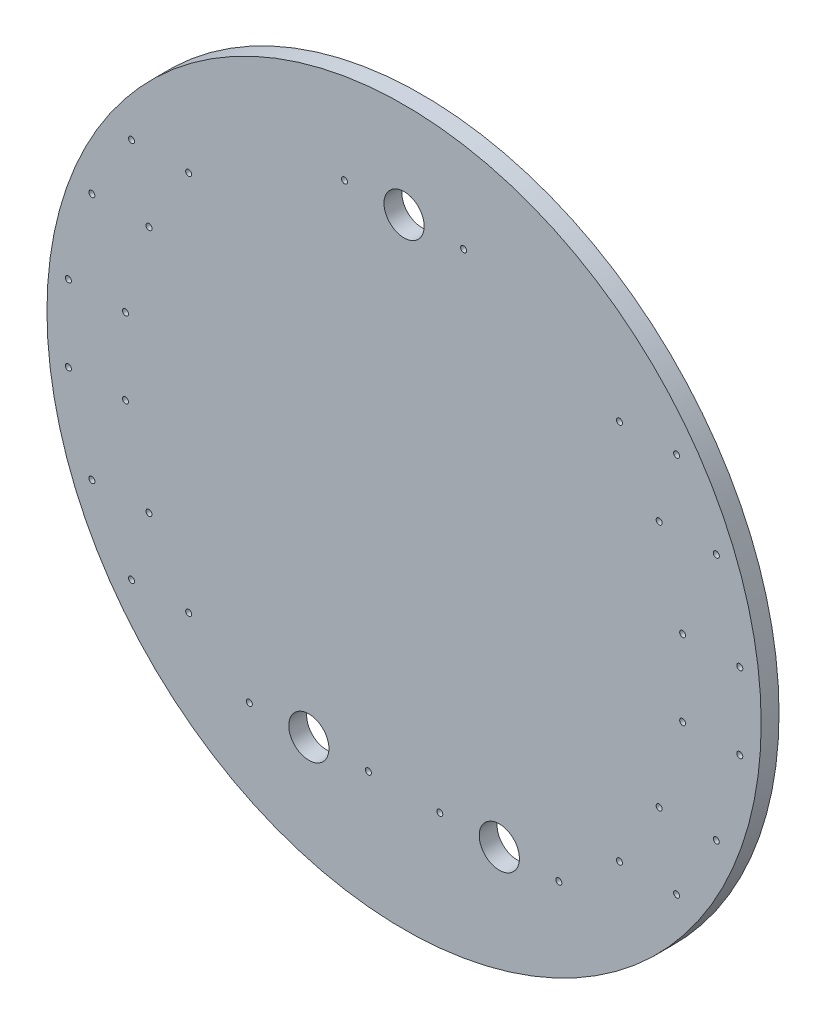
from build123d import *

# Parameters (mm, degrees)
SKETCH1_R                   = 95.25
BOSS_EXTRUDE1_DEPTH         = 4.7625
M2X0_4_TAPPED_HOLE1_D       = 1.6
M2X0_4_TAPPED_HOLE1_DEPTH   = 5.334
M2X0_4_TAPPED_HOLE2_D       = 1.6
M2X0_4_TAPPED_HOLE2_DEPTH   = 5.334
F_1_2_13_TAPPED_HOLE1_D     = 10.71626
F_1_2_13_TAPPED_HOLE1_DEPTH = 31.242


with BuildPart() as part:
    # Sketch1 → Boss-Extrude1 (new body)
    with BuildSketch(Plane.XY):
        Circle(SKETCH1_R)
    extrude(amount=BOSS_EXTRUDE1_DEPTH)

    # M2x0.4 Tapped Hole1
    with Locations(Plane.XY.offset(4.7625)):
        with Locations((-83.278324724, 33.02), (-68.038324724, 33.02), (-72.688137364, 50.8), (-57.448137364, 50.8), (-89.542383388, 10.16), (-74.302383388, 10.16), (-57.448137364, -50.8), (-72.688137364, -50.8), (-68.038324724, -33.02), (-83.278324724, -33.02), (-74.302383388, -10.16), (-89.542383388, -10.16), (57.448137364, -50.8), (72.688137364, -50.8), (68.038324724, -33.02), (83.278324724, -33.02), (89.542383388, -10.16), (74.302383388, -10.16), (89.542383388, 10.16), (74.302383388, 10.16), (83.278324724, 33.02), (68.038324724, 33.02), (57.448137364, 50.8), (72.688137364, 50.8)):
            Hole(M2X0_4_TAPPED_HOLE1_D / 2, depth=M2X0_4_TAPPED_HOLE1_DEPTH)

    # M2x0.4 Tapped Hole2
    with Locations(Plane.XY.offset(4.7625)):
        with Locations((-41.275, -63.5), (-9.525, -63.5), (9.525, -63.5), (41.275, -63.5), (-15.875, 69.85), (15.875, 69.85)):
            Hole(M2X0_4_TAPPED_HOLE2_D / 2, depth=M2X0_4_TAPPED_HOLE2_DEPTH)

    # 1/2-13 Tapped Hole1
    with Locations(Plane.XY.offset(4.7625)):
        with Locations((0, 69.85), (-25.4, -63.5), (25.4, -63.5)):
            Hole(F_1_2_13_TAPPED_HOLE1_D / 2, depth=F_1_2_13_TAPPED_HOLE1_DEPTH)


solid = part.part
